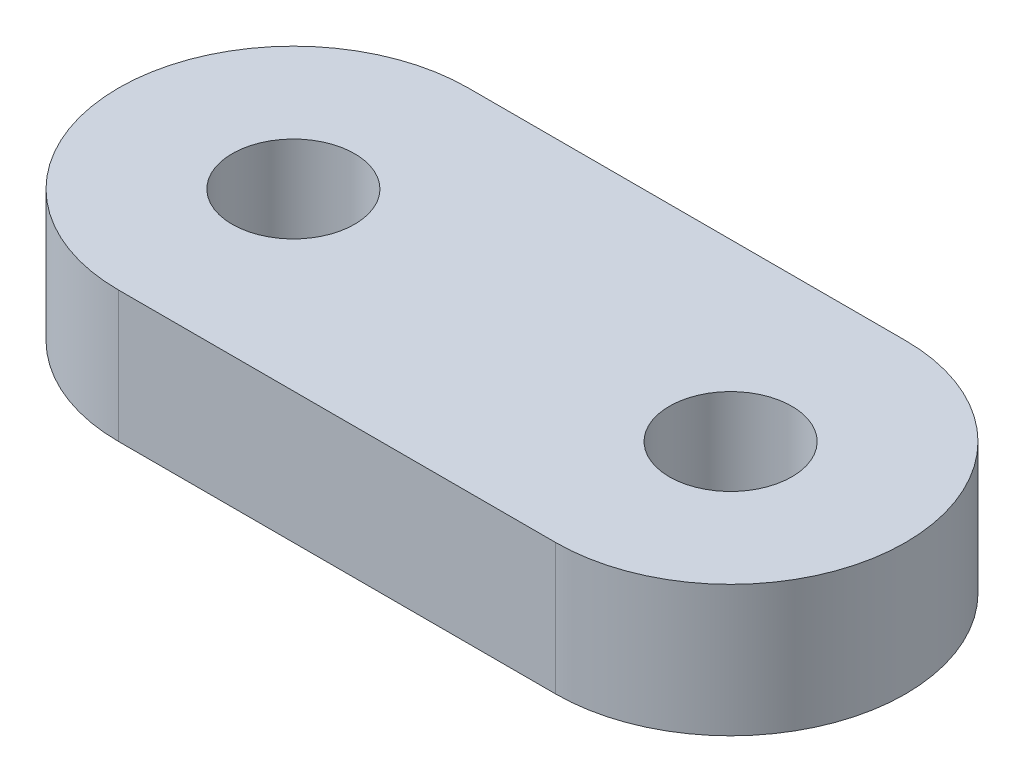
from build123d import *

# Parameters (mm, degrees)
SKETCH1_R           = 1.4
BOSS_EXTRUDE1_DEPTH = 3


with BuildPart() as part:
    # Sketch1 → Boss-Extrude1 (new body)
    with BuildSketch(Plane(origin=(0, 0, 0), x_dir=(1, 0, 0), z_dir=(0, 1, 0))):
        with BuildLine():
            Line((5.000900978, 3.998873518), (-4.999098768, 4.001126279))
            ThreePointArc((-4.999098768, 4.001126279), (-8.999999772, 0.002027486), (-5.000900978, -3.998873518))
            Line((-5.000900978, -3.998873518), (4.999098768, -4.001126279))
            ThreePointArc((4.999098768, -4.001126279), (8.999999772, -0.002027486), (5.000900978, 3.998873518))
        make_face()
        with Locations((4.999999873, -0.001126381)):
            Circle(SKETCH1_R, mode=Mode.SUBTRACT)
        with Locations((-4.999999873, 0.001126381)):
            Circle(SKETCH1_R, mode=Mode.SUBTRACT)
    extrude(amount=BOSS_EXTRUDE1_DEPTH)


solid = part.part
